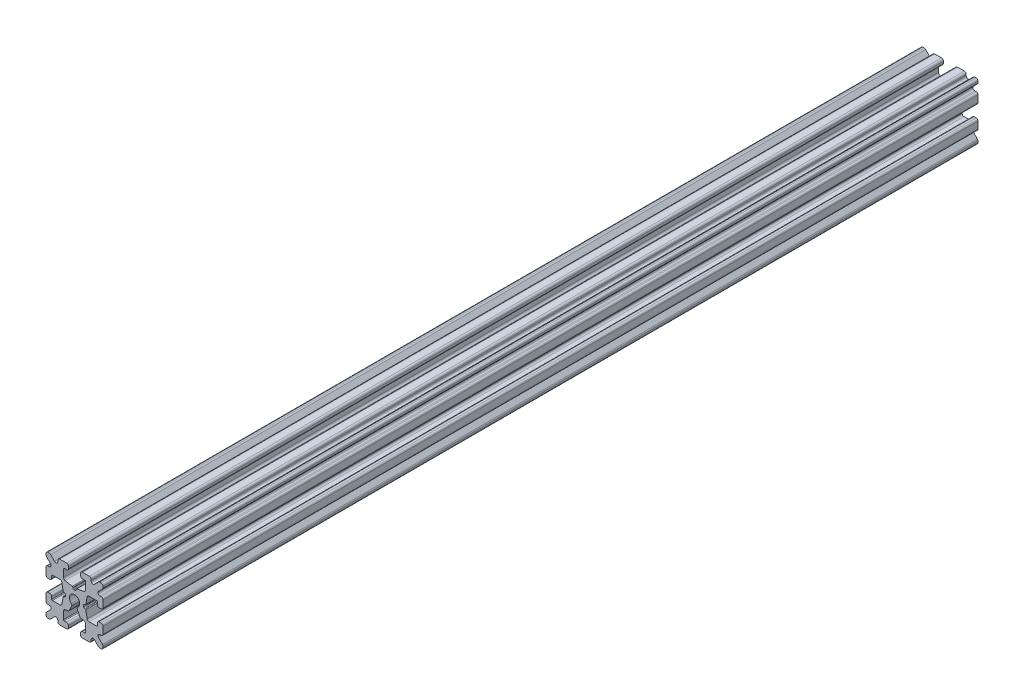
from build123d import *

# Parameters (mm, degrees)
SKETCH1_W           = 15
SKETCH1_H           = 15
SKETCH1_R           = 1.35
BOSS_EXTRUDE1_DEPTH = 115.1
FILLET1_R           = 0.5
CUT_EXTRUDE1_DEPTH  = 231.2
CUT_EXTRUDE3_DEPTH  = 231.2
FILLET3_R           = 0.5
FILLET4_R           = 0.5
FILLET5_R           = 3
FILLET6_R           = 0.2
CUT_EXTRUDE4_DEPTH  = 231.2
FILLET8_R           = 0.5
SKETCH6_W           = 6.249171159
SKETCH6_H           = 0.889
SKETCH6_W_2         = 0.889
SKETCH6_H_2         = 6.249171159
CUT_EXTRUDE5_DEPTH  = 231.2
CUT_EXTRUDE6_DEPTH  = 231.2
FILLET9_R           = 0.5
FILLET10_R          = 0.2


with BuildPart() as part:
    # Sketch1 → Boss-Extrude1 (new body, symmetric)
    with BuildSketch(Plane.XY):
        Rectangle(SKETCH1_W, SKETCH1_H)
        Circle(SKETCH1_R, mode=Mode.SUBTRACT)
    extrude(amount=BOSS_EXTRUDE1_DEPTH, both=True)

    # Fillet1
    fillet1_edges = [part.edges().sort_by_distance(p)[0] for p in [
        (7.5, -7.5, 0),
        (-7.5, -7.5, 0),
        (-7.5, 7.5, 0),
        (7.5, 7.5, 0),
    ]]
    fillet(fillet1_edges, radius=FILLET1_R)

    # Sketch2 → Cut-Extrude1 (cut, through all)
    with BuildSketch(Plane.XY.offset(115.1)):
        Polygon((-7.5, 1.6), (-6, 1.6), (-6, 2.9), (-3.4, 2.9), (-3.4, -2.9), (-6, -2.9), (-6, -1.6), (-7.5, -1.6), align=None)
        Polygon((2.9, 6), (1.6, 6), (1.6, 7.5), (-1.6, 7.5), (-1.6, 6), (-2.9, 6), (-2.9, 3.4), (2.9, 3.4), align=None)
        Polygon((-1.6, -7.5), (-1.6, -6), (-2.9, -6), (-2.9, -3.4), (2.9, -3.4), (2.9, -6), (1.6, -6), (1.6, -7.5), align=None)
        Polygon((6, -2.9), (6, -1.6), (7.5, -1.6), (7.5, 1.6), (6, 1.6), (6, 2.9), (3.4, 2.9), (3.4, -2.9), align=None)
    extrude(amount=-CUT_EXTRUDE1_DEPTH, mode=Mode.SUBTRACT)

    # Sketch4 → Cut-Extrude3 (cut, through all)
    with BuildSketch(Plane.XY.offset(115.1)):
        Polygon((-3.4, 2.9), (-2.85, 0), (-3.4, -2.9), align=None)
        Polygon((-2.9, 3.4), (0, 2.85), (2.9, 3.4), align=None)
        Polygon((3.4, 2.9), (2.85, 0), (3.4, -2.9), align=None)
        Polygon((-2.9, -3.4), (0, -2.85), (2.9, -3.4), align=None)
    extrude(amount=-CUT_EXTRUDE3_DEPTH, mode=Mode.SUBTRACT)

    # Fillet3
    fillet3_edges = [part.edges().sort_by_distance(p)[0] for p in [
        (1.6, -7.5, 0),
        (-1.6, -7.5, 0),
        (-1.6, -6, 0),
        (1.6, -6, 0),
        (6, 1.6, 0),
        (7.5, 1.6, 0),
        (7.5, -1.6, 0),
        (6, -1.6, 0),
        (-7.5, -1.6, 0),
        (-7.5, 1.6, 0),
        (-6, 1.6, 0),
        (-6, -1.6, 0),
        (-1.6, 6, 0),
        (-1.6, 7.5, 0),
        (1.6, 7.5, 0),
        (1.6, 6, 0),
    ]]
    fillet(fillet3_edges, radius=FILLET3_R)

    # Fillet4
    fillet4_edges = [part.edges().sort_by_distance(p)[0] for p in [
        (-2.9, -3.4, 0),
        (2.9, -3.4, 0),
        (3.4, -2.9, 0),
        (3.4, 2.9, 0),
        (-3.4, 2.9, 0),
        (-3.4, -2.9, 0),
        (2.9, 3.4, 0),
        (-2.9, 3.4, 0),
    ]]
    fillet(fillet4_edges, radius=FILLET4_R)

    # Fillet5
    fillet5_edges = [part.edges().sort_by_distance(p)[0] for p in [
        (-2.85, 0, 0),
        (0, 2.85, 0),
        (2.85, 0, 0),
        (0, -2.85, 0),
    ]]
    fillet(fillet5_edges, radius=FILLET5_R)

    # Fillet6
    fillet6_edges = [part.edges().sort_by_distance(p)[0] for p in [
        (-2.9, -6, 0),
        (2.9, -6, 0),
        (6, -2.9, 0),
        (6, 2.9, 0),
        (-6, 2.9, 0),
        (-6, -2.9, 0),
        (2.9, 6, 0),
        (-2.9, 6, 0),
    ]]
    fillet(fillet6_edges, radius=FILLET6_R)

    # Sketch5 → Cut-Extrude4 (cut, through all)
    with BuildSketch(Plane.XY.offset(115.1)):
        Polygon((-7.5, 6.439339828), (-5.460660172, 4.4), (-7.5, 4.4), align=None)
        Polygon((-6.439339828, 7.5), (-4.4, 5.460660172), (-4.4, 7.5), align=None)
        Polygon((4.4, 7.5), (6.439339828, 7.5), (4.4, 5.460660172), align=None)
        Polygon((7.5, 6.439339828), (7.5, 4.4), (5.460660172, 4.4), align=None)
        Polygon((7.5, -6.439339828), (5.460660172, -4.4), (7.5, -4.4), align=None)
        Polygon((6.439339828, -7.5), (4.4, -5.460660172), (4.4, -7.5), align=None)
        Polygon((-4.4, -7.5), (-6.439339828, -7.5), (-4.4, -5.460660172), align=None)
        Polygon((-7.5, -6.439339828), (-7.5, -4.4), (-5.460660172, -4.4), align=None)
    extrude(amount=-CUT_EXTRUDE4_DEPTH, mode=Mode.SUBTRACT)

    # Fillet8
    fillet8_edges = [part.edges().sort_by_distance(p)[0] for p in [
        (-7.5, 4.4, 0),
        (-7.5, 6.439339828, 0),
        (-5.460660172, 4.4, 0),
        (7.5, -4.4, 0),
        (7.5, -6.439339828, 0),
        (5.460660172, -4.4, 0),
        (5.460660172, 4.4, 0),
        (7.5, 6.439339828, 0),
        (7.5, 4.4, 0),
        (-4.4, 7.5, 0),
        (-4.4, 5.460660172, 0),
        (-6.439339828, 7.5, 0),
        (-5.460660172, -4.4, 0),
        (-7.5, -6.439339828, 0),
        (-7.5, -4.4, 0),
        (4.4, 5.460660172, 0),
        (4.4, 7.5, 0),
        (6.439339828, 7.5, 0),
        (6.439339828, -7.5, 0),
        (4.4, -7.5, 0),
        (4.4, -5.460660172, 0),
        (-6.439339828, -7.5, 0),
        (-4.4, -5.460660172, 0),
        (-4.4, -7.5, 0),
    ]]
    fillet(fillet8_edges, radius=FILLET8_R)

    # Sketch6 → Cut-Extrude5 (cut, through all)
    with BuildSketch(Plane.XY.offset(115.1)):
        with Locations((5.530603002, 0)):
            Rectangle(SKETCH6_W, SKETCH6_H)
        with Locations((-5.530603002, 0)):
            Rectangle(SKETCH6_W, SKETCH6_H)
        with Locations((0, 5.530603002)):
            Rectangle(SKETCH6_W_2, SKETCH6_H_2)
    extrude(amount=-CUT_EXTRUDE5_DEPTH, mode=Mode.SUBTRACT)

    # Sketch7 → Cut-Extrude6 (cut, through all)
    with BuildSketch(Plane.XY.offset(115.1)):
        Polygon((0, 0), (-2.153335353, -4.617842566), (2.153335353, -4.617842566), align=None)
    extrude(amount=-CUT_EXTRUDE6_DEPTH, mode=Mode.SUBTRACT)

    # Fillet9
    fillet9_edges = [part.edges().sort_by_distance(p)[0] for p in [
        (1.457911068, -3.126500375, 0),
        (-1.457911068, -3.126500375, 0),
        (-0.570534653, -1.223515512, 0),
        (0.570534653, -1.223515512, 0),
    ]]
    fillet(fillet9_edges, radius=FILLET9_R)

    # Fillet10
    fillet10_edges = [part.edges().sort_by_distance(p)[0] for p in [
        (-2.406017422, 0.4445, 0),
        (-2.406017422, -0.4445, 0),
        (0.4445, 2.406017422, 0),
        (-0.4445, 2.406017422, 0),
        (2.406017422, 0.4445, 0),
        (2.406017422, -0.4445, 0),
        (-2.93658978, -0.4445, 0),
        (-2.93658978, 0.4445, 0),
        (2.93658978, -0.4445, 0),
        (2.93658978, 0.4445, 0),
        (0.4445, 2.93658978, 0),
        (-0.4445, 2.93658978, 0),
    ]]
    fillet(fillet10_edges, radius=FILLET10_R)


solid = part.part
